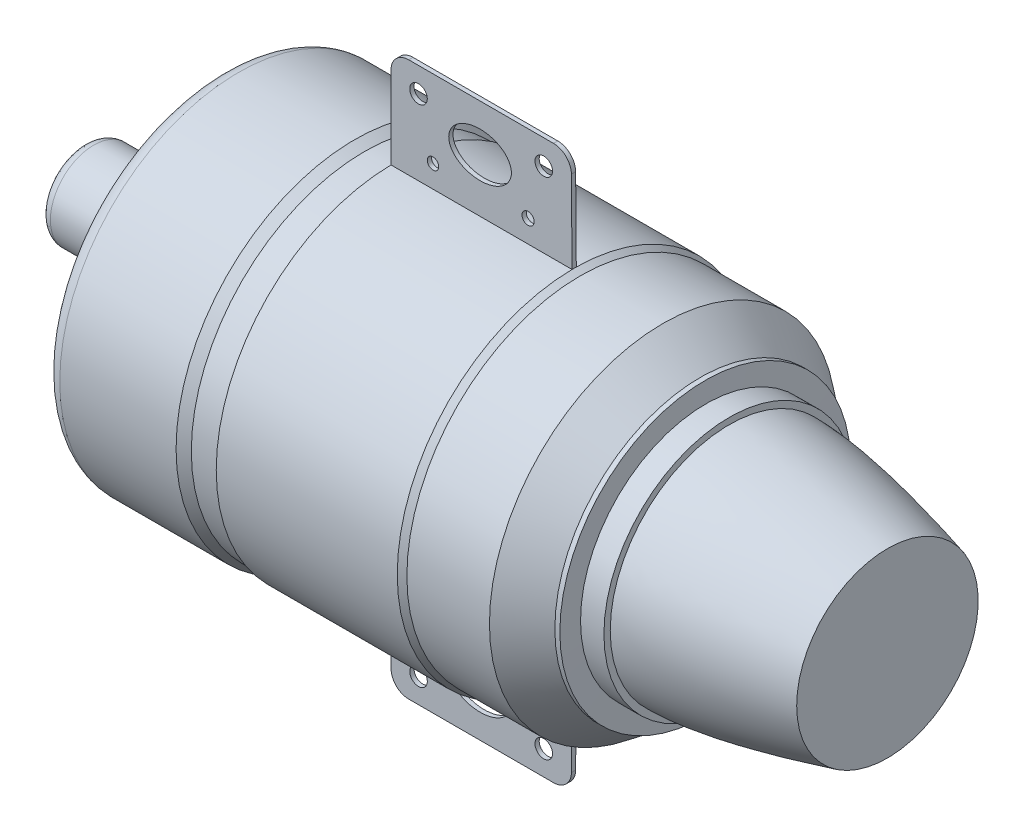
from build123d import *

# Parameters (mm, degrees)
SKETCH1_4_R         = 0.681301536
SKETCH1_4_R_2       = 0.723268125
BOSS_EXTRUDE1_DEPTH = 0.254
BOSS_EXTRUDE2_DEPTH = 1.27
CIRPATTERN1_COUNT   = 4
FILLET1_R           = 1.27
SCALE1_SCALE        = 2.276
SKETCH2_R           = 2.38125
CUT_EXTRUDE1_DEPTH  = 181.12773864


with BuildPart() as part:
    # Sketch1 → Revolve1 (revolve)
    with BuildSketch(Plane.XY):
        with BuildLine():
            Line((9.450406563, 5.172181663), (1.090462068, 5.172181663))
            ThreePointArc((1.090462068, 5.172181663), (0.275579454, 2.642942048), (0, 0))
            Line((0, 0), (9.450406563, 0))
            Line((9.450406563, 0), (9.450406563, 5.172181663))
        make_face()
        with BuildLine():
            Line((17.093728294, 18.913287876), (17.093728294, 0))
            Line((17.093728294, 0), (96.645248899, 0))
            Line((96.645248899, 0), (96.645248899, 10.827489794))
            add(Edge.make_bspline(
                [(77.770736546, 14.197719485), (83.967767677, 14.197719485), (96.645248899, 10.827489794)],
                knots=[0, 0, 0, 1, 1, 1], degree=2))
            Line((77.770736546, 14.197719485), (77.770736546, 14.952840317))
            Line((77.770736546, 14.952840317), (74.981675377, 14.952840317))
            Line((74.981675377, 14.952840317), (74.909379663, 17.349227048))
            Line((74.909379663, 17.349227048), (74.312442602, 17.349227048))
            Line((74.312442602, 17.349227048), (69.857537365, 20.695532843))
            Line((69.857537365, 20.695532843), (60.005153989, 20.695532843))
            Line((60.005153989, 20.695532843), (59.2694473, 21.107528589))
            Line((59.2694473, 21.107528589), (37.67078875, 21.107528589))
            Line((37.67078875, 21.107528589), (37.67078875, 20.65957324))
            Line((37.67078875, 20.65957324), (34.249634962, 20.65957324))
            Line((34.249634962, 20.65957324), (33.085444719, 21.311519777))
            Line((33.085444719, 21.311519777), (19.208297022, 21.311519777))
            ThreePointArc((19.208297022, 21.311519777), (17.697865454, 20.511952721), (17.093728294, 18.913287876))
        make_face()
    revolve(axis=Axis((-26.796271974, 0, 0), (1, 0, 0)))

    # Sketch1_4 → Boss-Extrude1 (add, symmetric)
    with BuildSketch(Plane.XY):
        with BuildLine():
            Line((37.67078875, 18.679077388), (59.2694473, 18.679077388))
            Line((59.2694473, 18.679077388), (59.2694473, 21.107528589))
            Line((59.2694473, 21.107528589), (59.192673253, 30.916009008))
            ThreePointArc((59.192673253, 30.916009008), (58.562948924, 32.411407764), (57.062667076, 33.029408208))
            Line((57.062667076, 33.029408208), (39.784187951, 33.029408208))
            ThreePointArc((39.784187951, 33.029408208), (38.289789045, 32.410407913), (37.67078875, 30.916009008))
            Line((37.67078875, 30.916009008), (37.67078875, 18.679077388))
        make_face()
        with Locations((42.682741772, 23.762393902)):
            Circle(SKETCH1_4_R, mode=Mode.SUBTRACT)
        with BuildLine():
            add(Edge.make_bspline(
                [(52.035652914, 27.463003731), (52.035652914, 32.075728112), (46.427708226, 29.769365921), (40.819763537, 27.463003731), (46.427708226, 25.156641541), (52.035652914, 22.85027935), (52.035652914, 27.463003731)],
                knots=[0, 0, 0, 2.094395102, 2.094395102, 4.188790205, 4.188790205, 6.283185307, 6.283185307, 6.283185307], degree=2, weights=[1, 0.5, 1, 0.5, 1, 0.5, 1]))
        make_face(mode=Mode.SUBTRACT)
        with Locations((54.025364363, 23.762393902)):
            Circle(SKETCH1_4_R_2, mode=Mode.SUBTRACT)
    boss_extrude1 = extrude(amount=BOSS_EXTRUDE1_DEPTH, both=True)

    # Sketch1_5 → Boss-Extrude2 (add, symmetric)
    with BuildSketch(Plane.XY):
        with BuildLine():
            ThreePointArc((11.014724068, 6.119928269), (10.364916389, 5.427600899), (9.450406563, 5.172181663))
            Line((9.450406563, 5.172181663), (9.450406563, 0))
            Line((9.450406563, 0), (12.123394722, 0))
            Line((12.123394722, 0), (12.123394722, 4.941548024))
            Line((12.123394722, 4.941548024), (17.093728294, 14.456770177))
            Line((17.093728294, 14.456770177), (17.093728294, 17.757592992))
            Line((17.093728294, 17.757592992), (11.971268091, 7.951139141))
            Line((11.971268091, 7.951139141), (11.014724068, 6.119928269))
        make_face()
    boss_extrude2 = extrude(amount=BOSS_EXTRUDE2_DEPTH, both=True)

    # Sketch1_6 → Cut-Revolve1 (revolve, cut)
    with BuildSketch(Plane.XY):
        with BuildLine():
            Line((9.450406563, 7.951139141), (9.450406563, 5.172181663))
            ThreePointArc((9.450406563, 5.172181663), (10.364916389, 5.427600899), (11.014724068, 6.119928269))
            Line((11.014724068, 6.119928269), (11.971268091, 7.951139141))
            Line((11.971268091, 7.951139141), (9.450406563, 7.951139141))
        make_face()
    cut_revolve1 = revolve(axis=Axis((-26.796271974, 0, 0), (1, 0, 0)), mode=Mode.SUBTRACT)

    # CirPattern1: Boss-Extrude2, Cut-Revolve1 ×4 about axis
    cirpattern1_axis = Axis((-26.796271974, 0, 0), (1, 0, 0))
    add([boss_extrude2.rotate(cirpattern1_axis, i * 360 / CIRPATTERN1_COUNT) for i in range(1, CIRPATTERN1_COUNT)])
    add([cut_revolve1.rotate(cirpattern1_axis, i * 360 / CIRPATTERN1_COUNT) for i in range(1, CIRPATTERN1_COUNT)], mode=Mode.SUBTRACT)

    # Mirror1: Boss-Extrude1 across plane
    add(boss_extrude1.mirror(Plane.ZX))

    # Fillet1
    fillet1_edges = [part.edges().sort_by_distance(p)[0] for p in [
        (1.090462068, -5.172181663, 0),
    ]]
    fillet(fillet1_edges, radius=FILLET1_R)


with BuildPart() as part_1:
    # Scale1: scaled about (50.004516039, 1.725e-06, 0)
    add(part.part.scale(SCALE1_SCALE).moved(Location((-63.805762466, -2.201e-06, 0))))

    # Sketch2 → Cut-Extrude1 (cut, through all)
    with BuildSketch(Plane.XY.offset(0.578104003)):
        with Locations((29.405893819, 68.5)):
            Circle(SKETCH2_R)
        with Locations((63.405893819, 68.5)):
            Circle(SKETCH2_R)
        with Locations((29.405893819, -68.5)):
            Circle(SKETCH2_R)
        with Locations((63.405893819, -68.5)):
            Circle(SKETCH2_R)
    extrude(amount=-CUT_EXTRUDE1_DEPTH, mode=Mode.SUBTRACT)


solid = part_1.part
